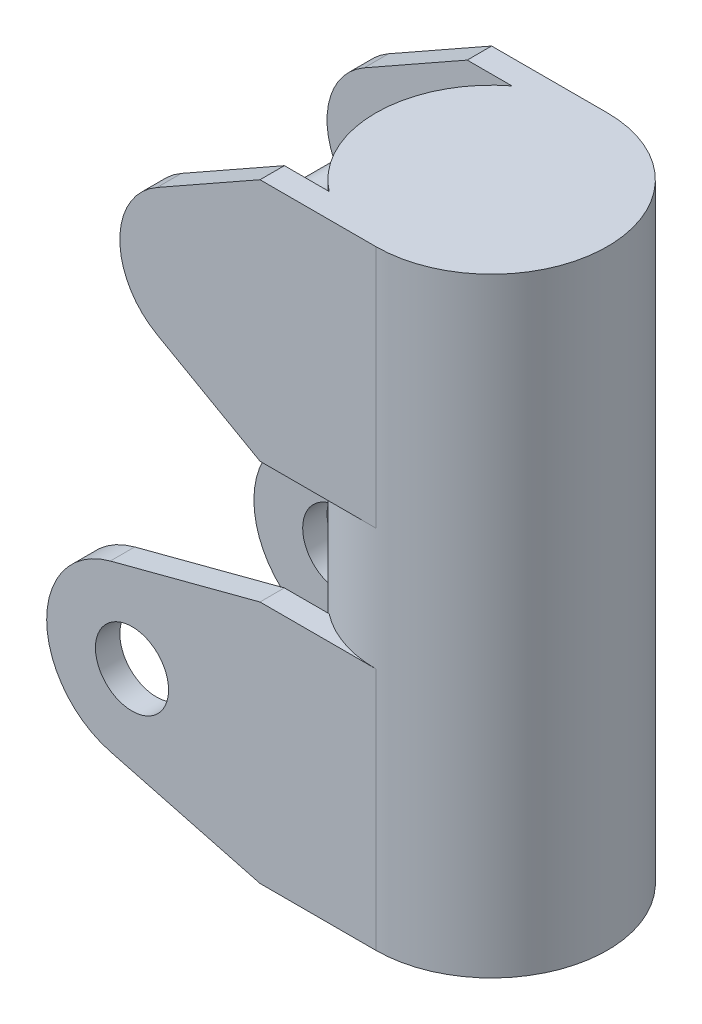
from build123d import *

# Parameters (mm, degrees)
SKETCH1_R           = 95
BOSS_EXTRUDE1_DEPTH = 500
SHELL1_T            = 10
SKETCH2_R           = 30
BOSS_EXTRUDE2_DEPTH = 20
SKETCH4_R           = 20
BOSS_EXTRUDE3_DEPTH = 95


with BuildPart() as part:
    # Sketch1 → Boss-Extrude1 (new body)
    with BuildSketch(Plane(origin=(0, 0, 0), x_dir=(1, 0, 0), z_dir=(0, 1, 0))):
        Circle(SKETCH1_R)
    extrude(amount=BOSS_EXTRUDE1_DEPTH)

    # Shell1 (no face opened: a closed hollow body)
    add(offset(amount=-SHELL1_T, mode=Mode.PRIVATE), mode=Mode.SUBTRACT)

    # Sketch2 → Boss-Extrude2 (add)
    with BuildSketch(Plane(origin=(0, 0, -95), x_dir=(-1, 0, 0), z_dir=(0, 0, -1))):
        with BuildLine():
            Line((0, 0), (95, 0))
            Line((95, 0), (217.806884991, 32.302770759))
            ThreePointArc((217.806884991, 32.302770759), (270, 100), (217.806884991, 167.697229241))
            Line((217.806884991, 167.697229241), (95, 200))
            Line((95, 200), (0, 200))
            Line((0, 200), (0, 0))
        make_face()
        with Locations((200, 100)):
            Circle(SKETCH2_R, mode=Mode.SUBTRACT)
        with BuildLine():
            Line((0, 500), (95, 500))
            Line((95, 500), (179.519741664, 452.235857915))
            ThreePointArc((179.519741664, 452.235857915), (210, 400), (179.519741664, 347.764142085))
            Line((179.519741664, 347.764142085), (95, 300))
            Line((95, 300), (0, 300))
            Line((0, 300), (0, 500))
        make_face()
    boss_extrude2 = extrude(amount=-BOSS_EXTRUDE2_DEPTH)

    # Mirror1: Boss-Extrude2 across plane
    add(boss_extrude2.mirror(Plane(origin=(0, 0, 0), x_dir=(1, 0, 0), z_dir=(0, 0, -1))))

    # Sketch4 → Boss-Extrude3 (add, symmetric)
    with BuildSketch(Plane.XY):
        with Locations((-150, 400)):
            Circle(SKETCH4_R)
    extrude(amount=BOSS_EXTRUDE3_DEPTH, both=True)


solid = part.part
